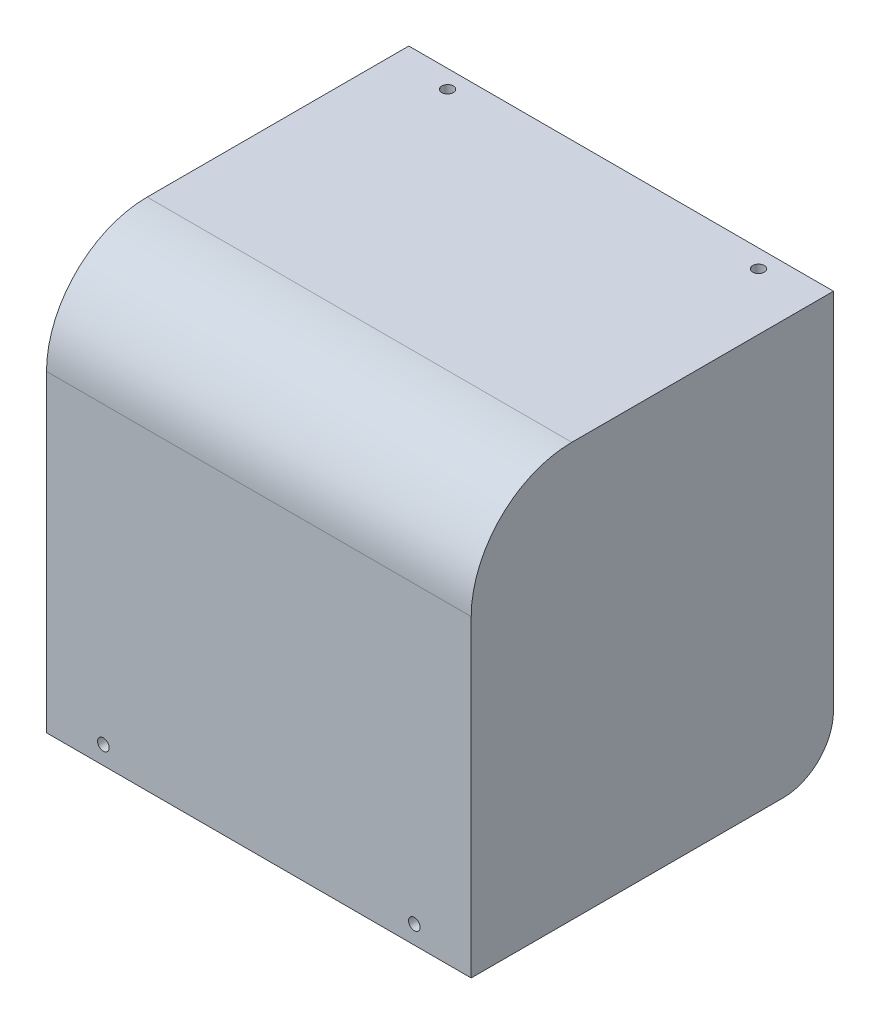
from build123d import *

# Parameters (mm, degrees)
BOSS_EXTRUDE1_DEPTH = 42.2
SKETCH2_R           = 1.15
CUT_EXTRUDE1_DEPTH  = 70
FILLET1_R           = 20
BOSS_EXTRUDE2_DEPTH = 2
FILLET2_R           = 10
SKETCH4_R           = 1.15
CUT_EXTRUDE2_DEPTH  = 10


with BuildPart() as part:
    # Sketch1 → Boss-Extrude1 (new body, symmetric)
    with BuildSketch(Plane(origin=(0, 0, 0), x_dir=(0, 0, -1), z_dir=(1, 0, 0))):
        Polygon((0, 0), (0, 82.2), (72, 82.2), (72, 80.2), (2, 80.2), (2, 0), align=None)
    extrude(amount=BOSS_EXTRUDE1_DEPTH, both=True)

    # Sketch2 → Cut-Extrude1 (cut)
    with BuildSketch(Plane.XY):
        with Locations((-30.9, 3.64)):
            Circle(SKETCH2_R)
        with Locations((30.9, 3.64)):
            Circle(SKETCH2_R)
    extrude(amount=-CUT_EXTRUDE1_DEPTH, mode=Mode.SUBTRACT)

    # Fillet1
    fillet1_edges = [part.edges().sort_by_distance(p)[0] for p in [
        (0, 82.2, 0),
        (0, 80.2, -2),
    ]]
    fillet(fillet1_edges, radius=FILLET1_R)

    # Sketch3 → Boss-Extrude2 (add)
    with BuildSketch(Plane.ZY.offset(42.2)):
        with BuildLine():
            Line((-72, 80.2), (-72, 0))
            Line((-72, 0), (-2, 0))
            Line((-2, 0), (-2, 60.2))
            ThreePointArc((-2, 60.2), (-7.857864376, 74.342135624), (-22, 80.2))
            Line((-22, 80.2), (-72, 80.2))
        make_face()
    boss_extrude2 = extrude(amount=-BOSS_EXTRUDE2_DEPTH)

    # Mirror1: Boss-Extrude2 across plane
    add(boss_extrude2.mirror(Plane(origin=(0, 0, 0), x_dir=(0, 0, 1), z_dir=(1, 0, 0))))

    # Fillet2
    fillet2_edges = [part.edges().sort_by_distance(p)[0] for p in [
        (-41.2, 0, -72),
        (41.2, 0, -72),
    ]]
    fillet(fillet2_edges, radius=FILLET2_R)

    # Sketch4 → Cut-Extrude2 (cut)
    with BuildSketch(Plane(origin=(0, 82.2, 0), x_dir=(1, 0, 0), z_dir=(0, 1, 0))):
        with Locations((-30.9, 68.401968)):
            Circle(SKETCH4_R)
        with Locations((30.9, 68.401968)):
            Circle(SKETCH4_R)
    extrude(amount=-CUT_EXTRUDE2_DEPTH, mode=Mode.SUBTRACT)


solid = part.part
